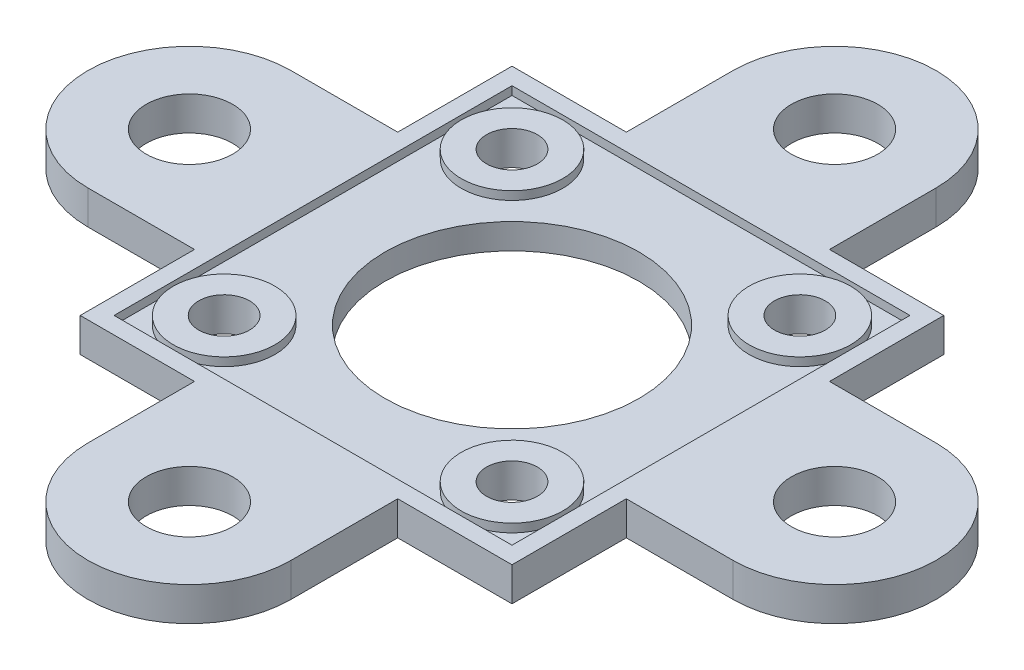
from build123d import *

# Parameters (mm, degrees)
SKETCH1_W           = 23
SKETCH1_H           = 23
SKETCH1_R           = 1.5
BOSS_EXTRUDE1_DEPTH = 1
SKETCH2_W           = 6
SKETCH2_H           = 5
BOSS_EXTRUDE2_DEPTH = 1
FILLET1_R           = 3
BOSS_EXTRUDE3_START = -3
SKETCH3_W           = 25.5
SKETCH3_H           = 25.5
SKETCH3_R           = 1.5
SKETCH3_R_2         = 7.5
BOSS_EXTRUDE3_DEPTH = 1.5
SKETCH4_R           = 3
SKETCH4_R_2         = 1.5
BOSS_EXTRUDE4_DEPTH = 2
SKETCH5_W           = 25.5
SKETCH5_H           = 25.5
SKETCH5_W_2         = 23.5
SKETCH5_H_2         = 23.5
BOSS_EXTRUDE5_DEPTH = 2
SKETCH6_R           = 2.5527
BOSS_EXTRUDE6_DEPTH = 2
CIRPATTERN1_COUNT   = 4


with BuildPart() as part:
    # Sketch1 → Boss-Extrude1 (new body)
    with BuildSketch(Plane(origin=(0, 0, 0), x_dir=(1, 0, 0), z_dir=(0, 1, 0))):
        Rectangle(SKETCH1_W, SKETCH1_H)
        with Locations((-8.5, 8.5)):
            Circle(SKETCH1_R, mode=Mode.SUBTRACT)
        with Locations((8.5, 8.5)):
            Circle(SKETCH1_R, mode=Mode.SUBTRACT)
        with Locations((8.5, -8.5)):
            Circle(SKETCH1_R, mode=Mode.SUBTRACT)
        with Locations((-8.5, -8.5)):
            Circle(SKETCH1_R, mode=Mode.SUBTRACT)
    extrude(amount=BOSS_EXTRUDE1_DEPTH)

    # Sketch2 → Boss-Extrude2 (add)
    with BuildSketch(Plane(origin=(0, 1, 0), x_dir=(1, 0, 0), z_dir=(0, 1, 0))):
        Rectangle(SKETCH2_W, SKETCH2_H)
    extrude(amount=BOSS_EXTRUDE2_DEPTH)

    # Fillet1
    fillet1_edges = [part.edges().sort_by_distance(p)[0] for p in [
        (11.5, 0.5, 11.5),
        (-11.5, 0.5, 11.5),
        (-11.5, 0.5, -11.5),
        (11.5, 0.5, -11.5),
    ]]
    fillet(fillet1_edges, radius=FILLET1_R)


with BuildPart() as body_2:
    # Sketch3 → Boss-Extrude3 (new body)
    with BuildSketch(Plane(origin=(0, 1, 0), x_dir=(1, 0, 0), z_dir=(0, 1, 0)).offset(BOSS_EXTRUDE3_START)):
        Rectangle(SKETCH3_W, SKETCH3_H)
        with Locations((-8.5, 8.5)):
            Circle(SKETCH3_R, mode=Mode.SUBTRACT)
        with Locations((8.5, 8.5)):
            Circle(SKETCH3_R, mode=Mode.SUBTRACT)
        with Locations((8.5, -8.5)):
            Circle(SKETCH3_R, mode=Mode.SUBTRACT)
        with Locations((-8.5, -8.5)):
            Circle(SKETCH3_R, mode=Mode.SUBTRACT)
        Circle(SKETCH3_R_2, mode=Mode.SUBTRACT)
    extrude(amount=BOSS_EXTRUDE3_DEPTH)

    # Sketch4 → Boss-Extrude4 (add)
    with BuildSketch(Plane.XZ.offset(2)):
        with Locations((-8.5, 8.5)):
            Circle(SKETCH4_R)
        with Locations((-8.5, 8.5)):
            Circle(SKETCH4_R_2, mode=Mode.SUBTRACT)
        with Locations((8.5, 8.5)):
            Circle(SKETCH4_R)
        with Locations((8.5, 8.5)):
            Circle(SKETCH4_R_2, mode=Mode.SUBTRACT)
        with Locations((8.5, -8.5)):
            Circle(SKETCH4_R)
        with Locations((8.5, -8.5)):
            Circle(SKETCH4_R_2, mode=Mode.SUBTRACT)
        with Locations((-8.5, -8.5)):
            Circle(SKETCH4_R)
        with Locations((-8.5, -8.5)):
            Circle(SKETCH4_R_2, mode=Mode.SUBTRACT)
    extrude(amount=-BOSS_EXTRUDE4_DEPTH)

    # Sketch5 → Boss-Extrude5 (add)
    with BuildSketch(Plane.XZ.offset(2)):
        Rectangle(SKETCH5_W, SKETCH5_H)
        Rectangle(SKETCH5_W_2, SKETCH5_H_2, mode=Mode.SUBTRACT)
    extrude(amount=-BOSS_EXTRUDE5_DEPTH)

    # Sketch6 → Boss-Extrude6 (add)
    with BuildSketch(Plane(origin=(0, 0, 0), x_dir=(-1, 0, 0), z_dir=(0, 1, 0))):
        with BuildLine():
            Line((-6, -19.05), (-6, -12.75))
            Line((-6, -12.75), (6, -12.75))
            Line((6, -12.75), (6, -19.05))
            ThreePointArc((6, -19.05), (0, -25.05), (-6, -19.05))
        make_face()
        with Locations((0, -19.05)):
            Circle(SKETCH6_R, mode=Mode.SUBTRACT)
    boss_extrude6 = extrude(amount=-BOSS_EXTRUDE6_DEPTH)

    # CirPattern1: Boss-Extrude6 ×4 about axis
    cirpattern1_axis = Axis((0, 0, 0), (0, 1, 0))
    for i in range(1, CIRPATTERN1_COUNT):
        add(boss_extrude6.rotate(cirpattern1_axis, i * 360 / CIRPATTERN1_COUNT))


solid = body_2.part
